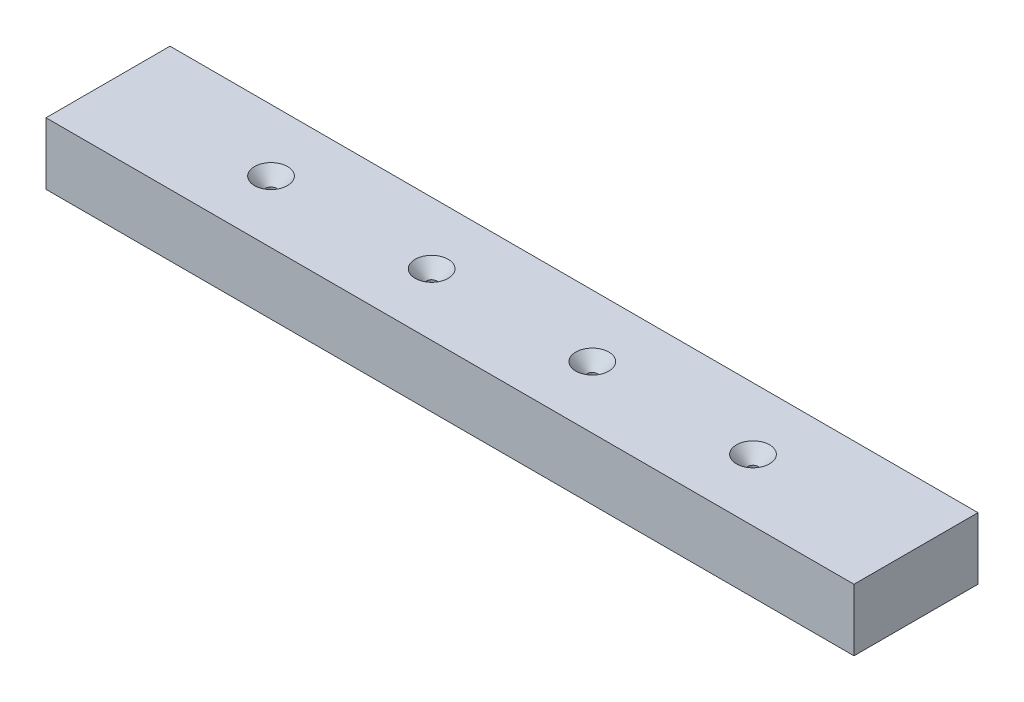
from build123d import *

# Parameters (mm, degrees)
SKETCH1_W           = 248.25
SKETCH1_H           = 19.05
BOSS_EXTRUDE1_DEPTH = 38.1
HOLE1_D             = 3.175
HOLE1_DEPTH         = 31.75
HOLE1_CSINK_D       = 10.16
HOLE1_CSINK_ANGLE   = 82
HOLE1_TIP           = 0.953866233
HOLE2_D             = 3.175
HOLE2_DEPTH         = 57.15
HOLE2_CSINK_D       = 10.16
HOLE2_CSINK_ANGLE   = 82
HOLE2_TIP           = 0.953866233


with BuildPart() as part:
    # Sketch1 → Boss-Extrude1 (new body)
    with BuildSketch(Plane.XY):
        with Locations((124.125, 47.625)):
            Rectangle(SKETCH1_W, SKETCH1_H)
    extrude(amount=BOSS_EXTRUDE1_DEPTH)

    # Hole1
    with Locations(Plane(origin=(-1090.512770337, -52.974999997, -12.7), x_dir=(0, 1, 0), z_dir=(0, 0, -1))):
        with Locations((-100.332047386, 1313.362770337), (100.599999997, 1313.362770337), (100.599999997, 1115.912770337), (100.599999997, 1214.637770337), (-100.332047386, 1214.637770337), (-100.332047386, 1115.912770337)):
            CounterSinkHole(HOLE1_D / 2, HOLE1_CSINK_D / 2, depth=HOLE1_DEPTH, counter_sink_angle=HOLE1_CSINK_ANGLE)
            with Locations((0, 0, -(HOLE1_DEPTH + HOLE1_TIP / 2))):  # 118° drill point
                Cone(0, HOLE1_D / 2, HOLE1_TIP, mode=Mode.SUBTRACT)

    # Hole2
    with Locations(Plane(origin=(-1090.512770337, 57.15, -415.792401694), x_dir=(0.374606593, 0, 0.927183855), z_dir=(0, 1, 0))):
        with Locations((848.944412528, 940.413642522), (885.927448463, 1031.949868564), (867.435930496, 986.181755543), (830.452894561, 894.645529501)):
            CounterSinkHole(HOLE2_D / 2, HOLE2_CSINK_D / 2, depth=HOLE2_DEPTH, counter_sink_angle=HOLE2_CSINK_ANGLE)
            with Locations((0, 0, -(HOLE2_DEPTH + HOLE2_TIP / 2))):  # 118° drill point
                Cone(0, HOLE2_D / 2, HOLE2_TIP, mode=Mode.SUBTRACT)


solid = part.part
